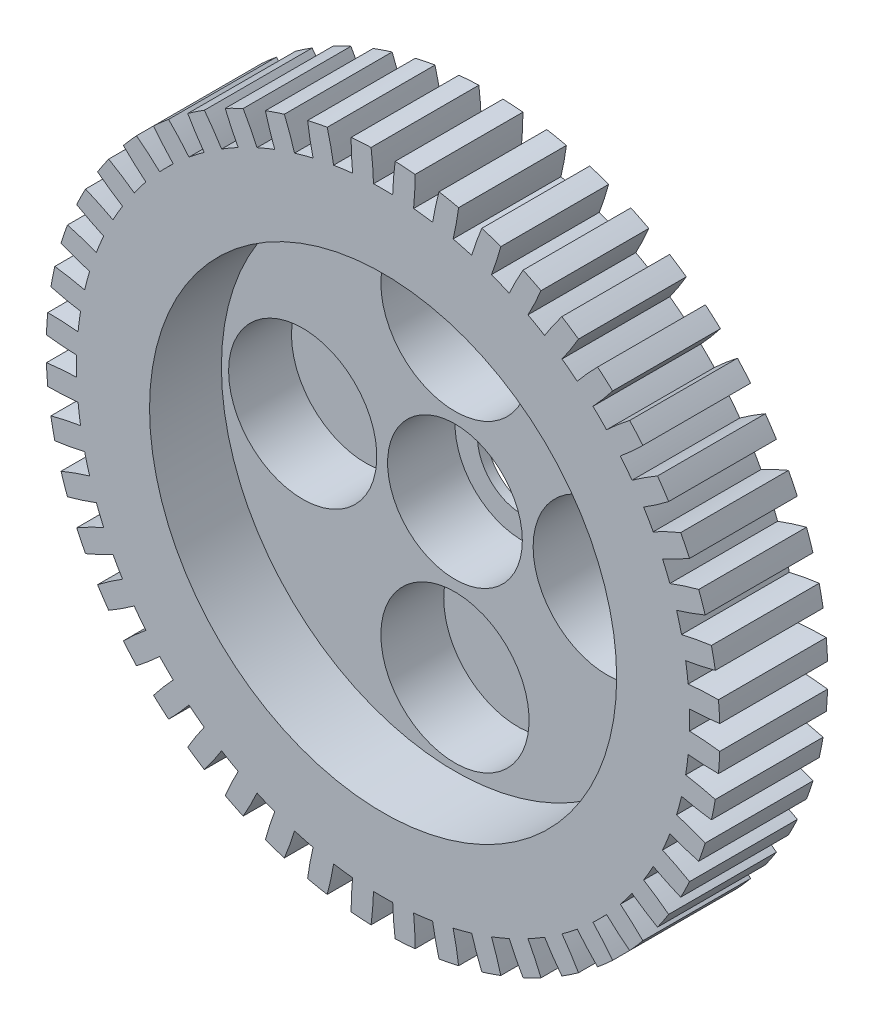
from build123d import *

# Parameters (mm, degrees)
SCHIZZO1_R                   = 37.5
ESTRUSIONE_ESTRUSIONE2_DEPTH = 12
SCHIZZO8_R                   = 30
TAGLIO_ESTRUSIONE4_DEPTH     = 2
SCHIZZO2_R                   = 26
TAGLIO_ESTRUSIONE1_DEPTH     = 8
ESTRUSIONE_ESTRUSIONE3_START = -2
SCHIZZO4_R                   = 8.5
SCHIZZO4_R_2                 = 5
ESTRUSIONE_ESTRUSIONE3_DEPTH = 6.5
SCHIZZO3_R                   = 7.5
TAGLIO_ESTRUSIONE2_DEPTH     = 7.5
ESTRUSIONE_ESTRUSIONE6_START = -2
SCHIZZO5_R                   = 9.25
ESTRUSIONE_ESTRUSIONE6_DEPTH = 6.5
TAGLIO_ESTRUSIONE3_START     = -8.5
SCHIZZO6_R                   = 8.25
TAGLIO_ESTRUSIONE3_DEPTH     = 7
TAGLIO_ESTRUSIONE6_DEPTH     = 17.5
RIPETIZIONECIRCOLARE2_COUNT  = 48


with BuildPart() as part:
    # Schizzo1 → Estrusione-Estrusione2 (new body)
    with BuildSketch(Plane.XY):
        Circle(SCHIZZO1_R)
    extrude(amount=ESTRUSIONE_ESTRUSIONE2_DEPTH)

    # Schizzo8 → Taglio-Estrusione4 (cut)
    with BuildSketch(Plane(origin=(0, 0, 0), x_dir=(-1, 0, 0), z_dir=(0, 0, -1))):
        Circle(SCHIZZO8_R)
    extrude(amount=-TAGLIO_ESTRUSIONE4_DEPTH, mode=Mode.SUBTRACT)

    # Schizzo2 → Taglio-Estrusione1 (cut)
    with BuildSketch(Plane.XY.offset(12)):
        Circle(SCHIZZO2_R)
    extrude(amount=-TAGLIO_ESTRUSIONE1_DEPTH, mode=Mode.SUBTRACT)

    # Schizzo4 → Estrusione-Estrusione3 (add)
    with BuildSketch(Plane(origin=(0, 0, 0), x_dir=(-1, 0, 0), z_dir=(0, 0, -1)).offset(ESTRUSIONE_ESTRUSIONE3_START)):
        Circle(SCHIZZO4_R)
        Circle(SCHIZZO4_R_2, mode=Mode.SUBTRACT)
    extrude(amount=ESTRUSIONE_ESTRUSIONE3_DEPTH)

    # Schizzo3 → Taglio-Estrusione2 (cut)
    with BuildSketch(Plane.XY.offset(4)):
        Circle(SCHIZZO3_R)
    extrude(amount=-TAGLIO_ESTRUSIONE2_DEPTH, mode=Mode.SUBTRACT)

    # Schizzo5 → Estrusione-Estrusione6 (add)
    with BuildSketch(Plane(origin=(0, 0, 0), x_dir=(-1, 0, 0), z_dir=(0, 0, -1)).offset(ESTRUSIONE_ESTRUSIONE6_START)):
        with Locations((0, 16.95)):
            Circle(SCHIZZO5_R)
        with Locations((16.95, 0)):
            Circle(SCHIZZO5_R)
        with Locations((0, -16.95)):
            Circle(SCHIZZO5_R)
        with Locations((-16.95, 0)):
            Circle(SCHIZZO5_R)
    extrude(amount=ESTRUSIONE_ESTRUSIONE6_DEPTH)

    # Schizzo6 → Taglio-Estrusione3 (cut)
    with BuildSketch(Plane(origin=(0, 0, -4.5), x_dir=(-1, 0, 0), z_dir=(0, 0, -1)).offset(TAGLIO_ESTRUSIONE3_START)):
        with Locations((0, 16.95)):
            Circle(SCHIZZO6_R)
        with Locations((16.95, 0)):
            Circle(SCHIZZO6_R)
        with Locations((0, -16.95)):
            Circle(SCHIZZO6_R)
        with Locations((-16.95, 0)):
            Circle(SCHIZZO6_R)
    extrude(amount=TAGLIO_ESTRUSIONE3_DEPTH, mode=Mode.SUBTRACT)

    # Schizzo10 → Taglio-Estrusione6 (cut, through all)
    with BuildSketch(Plane.XY.offset(12)):
        with BuildLine():
            ThreePointArc((34.108292661, -1.067706314), (34.125, 0), (34.108292661, 1.067706314))
            add(Edge.make_bspline(
                [(37.476055425, 1.339876784), (37.332532722, 1.321092532), (36.974063072, 1.276002944), (36.40921505, 1.212311146), (35.642631474, 1.148204406), (35.039019274, 1.105513128), (34.431609048, 1.0791578), (34.217244608, 1.071116883), (34.108292661, 1.067706314)],
                knots=[0.889606954, 0.889606954, 0.889606954, 0.889606954, 0.889606954, 0.894247178, 0.901268177, 0.908289176, 0.912472798, 0.916656419, 0.916656419, 0.916656419, 0.916656419, 0.916656419], degree=4))
            ThreePointArc((37.476055425, 1.339876784), (37.5, 0), (37.476055425, -1.339876784))
            add(Edge.make_bspline(
                [(37.476055425, -1.339876784), (37.332532722, -1.321092532), (36.974063072, -1.276002944), (36.40921505, -1.212311146), (35.642631474, -1.148204406), (35.039019274, -1.105513128), (34.431609048, -1.0791578), (34.217244608, -1.071116883), (34.108292661, -1.067706314)],
                knots=[0.889606954, 0.889606954, 0.889606954, 0.889606954, 0.889606954, 0.894247178, 0.901268177, 0.908289176, 0.912472798, 0.916656419, 0.916656419, 0.916656419, 0.916656419, 0.916656419], degree=4))
        make_face()
    taglio_estrusione6 = extrude(amount=-TAGLIO_ESTRUSIONE6_DEPTH, mode=Mode.SUBTRACT)

    # RipetizioneCircolare2: Taglio-Estrusione6 ×48 about axis
    ripetizionecircolare2_axis = Axis((0, 0, 0), (0, 0, -1))
    for i in range(1, RIPETIZIONECIRCOLARE2_COUNT):
        add(taglio_estrusione6.rotate(ripetizionecircolare2_axis, i * 360 / RIPETIZIONECIRCOLARE2_COUNT), mode=Mode.SUBTRACT)


solid = part.part
